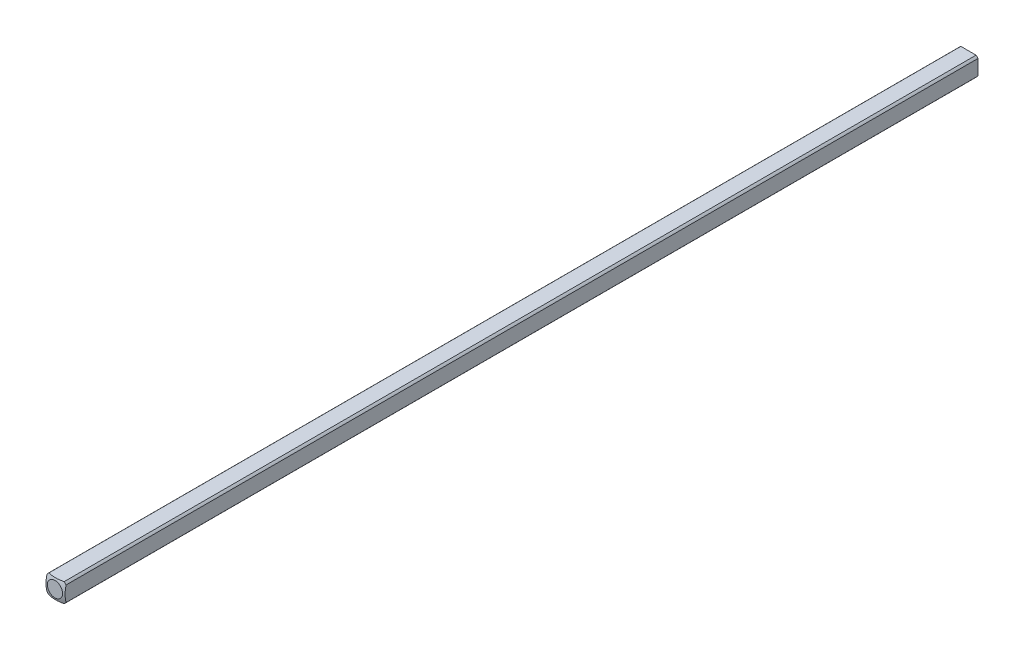
from build123d import *

# Parameters (mm, degrees)
SKETCH1_W           = 3.175
SKETCH1_H           = 3.175
BOSS_EXTRUDE1_DEPTH = 152.4
SKETCH2_OUTSIDE_W   = 35.668
SKETCH2_OUTSIDE_H   = 35.668
SKETCH2_OUTSIDE_R   = 2.032
CUT_EXTRUDE1_DEPTH  = 153.416535561
SKETCH4_W           = 152.4
SKETCH4_H           = 3.175
CUT_EXTRUDE3_DEPTH  = 305.820669872


with BuildPart() as part:
    # Sketch1 → Boss-Extrude1 (new body)
    with BuildSketch(Plane.XY):
        Rectangle(SKETCH1_W, SKETCH1_H)
    extrude(amount=BOSS_EXTRUDE1_DEPTH)

    # Sketch2 outside → Cut-Extrude1 (cut, through all)
    with BuildSketch(Plane(origin=(0, 0, 0), x_dir=(-1, 0, 0), z_dir=(0, 0, -1))):
        Rectangle(SKETCH2_OUTSIDE_W, SKETCH2_OUTSIDE_H)
        Circle(SKETCH2_OUTSIDE_R, mode=Mode.SUBTRACT)
    extrude(amount=-CUT_EXTRUDE1_DEPTH, mode=Mode.SUBTRACT)

    # Sketch3 → Cut-Revolve1 (revolve, cut)
    with BuildSketch(Plane(origin=(0, 0, 0), x_dir=(1, 0, 0), z_dir=(0, 1, 0))):
        with BuildLine():
            Line((-5.053685963, -4.40273269), (-5.053685963, 5.740530545))
            Line((-5.053685963, 5.740530545), (0, 5.740530545))
            Line((0, 5.740530545), (0, 0.160877736))
            ThreePointArc((0, 0.160877736), (-3.404639553, -1.148866368), (-5.053685963, -4.40273269))
        make_face()
    revolve(axis=Axis((0, 0, 152.4), (0, 0, -1)), mode=Mode.SUBTRACT)

    # Mirror1: part across plane


with BuildPart() as part_1:
    add(part.part)
    add(part.part.mirror(Plane(origin=(0, 0, 152.4), x_dir=(1, 0, 0), z_dir=(0, 0, -1))))

    # Sketch4 → Cut-Extrude3 (cut, through all)
    with BuildSketch(Plane(origin=(1.5875, 0, 0), x_dir=(0, 0, -1), z_dir=(1, 0, 0))):
        with Locations((-76.463225358, 0)):
            Rectangle(SKETCH4_W, SKETCH4_H)
    extrude(amount=-CUT_EXTRUDE3_DEPTH, mode=Mode.SUBTRACT)


with BuildPart() as body_2:
    # of the pieces the cut leaves, the one that is kept (cut_extrude3_keep)
    add(part_1.part.solids().sort_by_distance((1.268411507, -1.5875, 152.663225358))[0])


solid = body_2.part
